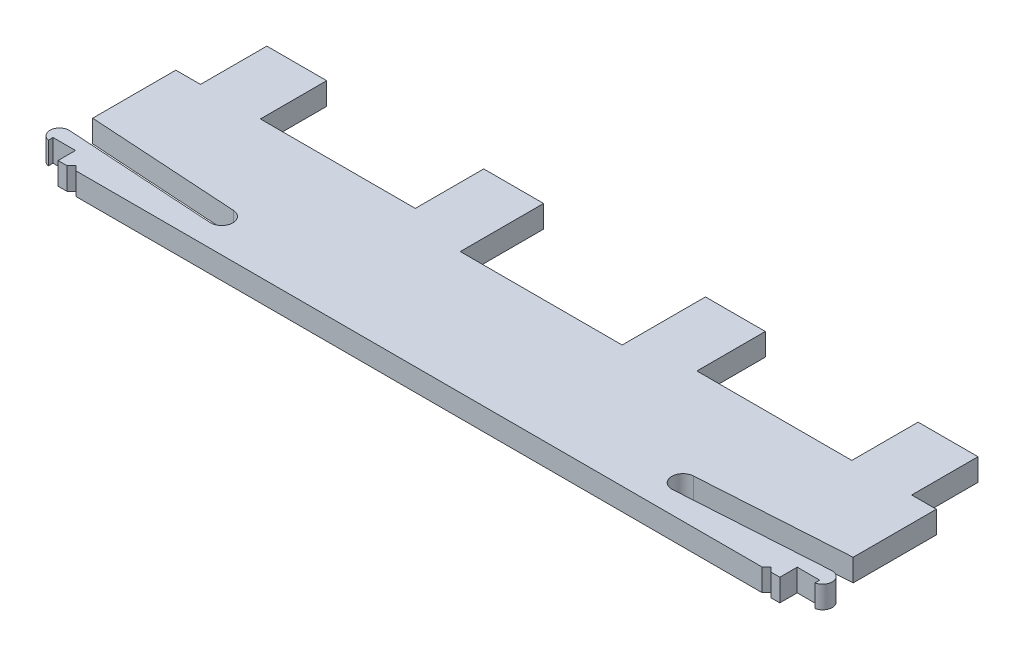
from build123d import *

# Parameters (mm, degrees)
BOSS_EXTRUDE1_DEPTH = 2.3622


with BuildPart() as part:
    # Sketch1 → Boss-Extrude1 (new body)
    with BuildSketch(Plane(origin=(0, 0, 0), x_dir=(1, 0, 0), z_dir=(0, 1, 0))):
        with BuildLine():
            Line((2.055202021, 14.546975478), (2.055202021, 5.72400467))
            Line((2.055202021, 5.72400467), (-13.894021226, 4.719731013))
            ThreePointArc((-13.894021226, 4.719731013), (-14.998563485, 3.466742259), (-13.745574731, 2.3622))
            Line((-13.745574731, 2.3622), (2.129425269, 3.361800046))
            ThreePointArc((2.129425269, 3.361800046), (3.201004497, 2.477166942), (2.3876, 1.350565462))
            Line((2.3876, 1.350565462), (2.3876, 1.846546672))
            Line((2.3876, 1.846546672), (0, 1.846546672))
            Line((0, 1.846546672), (0, 0))
            Line((0, 0), (-0.956548556, 0))
            Line((-0.956548556, 0), (-1.436625807, 0.480077251))
            Line((-1.436625807, 0.480077251), (-1.916703058, 0))
            Line((-1.916703058, 0), (-74.6432929, 0))
            Line((-74.6432929, 0), (-75.123370151, 0.480077251))
            Line((-75.123370151, 0.480077251), (-75.603447402, 0))
            Line((-75.603447402, 0), (-76.559995958, 0))
            Line((-76.559995958, 0), (-76.559995958, 1.846546672))
            Line((-76.559995958, 1.846546672), (-78.947595958, 1.846546672))
            Line((-78.947595958, 1.846546672), (-78.947595958, 1.350565462))
            ThreePointArc((-78.947595958, 1.350565462), (-79.761000455, 2.477166942), (-78.689421226, 3.361800046))
            Line((-78.689421226, 3.361800046), (-62.814421226, 2.3622))
            ThreePointArc((-62.814421226, 2.3622), (-61.561432472, 3.466742259), (-62.665974731, 4.719731013))
            Line((-62.665974731, 4.719731013), (-78.615197979, 5.72400467))
            Line((-78.615197979, 5.72400467), (-78.615197979, 14.546975478))
            Line((-78.615197979, 14.546975478), (-75.998997979, 14.546975478))
            Line((-75.998997979, 14.546975478), (-75.998997979, 21.582775478))
            Line((-75.998997979, 21.582775478), (-69.648997979, 21.582775478))
            Line((-69.648997979, 21.582775478), (-69.648997979, 14.546975478))
            Line((-69.648997979, 14.546975478), (-53.215197979, 14.546975478))
            Line((-53.215197979, 14.546975478), (-53.215197979, 21.806295525))
            Line((-53.215197979, 21.806295525), (-46.865197979, 21.806295525))
            Line((-46.865197979, 21.806295525), (-46.865197979, 12.967095525))
            Line((-46.865197979, 12.967095525), (-29.694797979, 12.967095525))
            Line((-29.694797979, 12.967095525), (-29.694797979, 21.806295525))
            Line((-29.694797979, 21.806295525), (-23.344797979, 21.806295525))
            Line((-23.344797979, 21.806295525), (-23.344797979, 14.546975478))
            Line((-23.344797979, 14.546975478), (-6.910997979, 14.546975478))
            Line((-6.910997979, 14.546975478), (-6.910997979, 21.582775478))
            Line((-6.910997979, 21.582775478), (-0.560997979, 21.582775478))
            Line((-0.560997979, 21.582775478), (-0.560997979, 14.546975478))
            Line((-0.560997979, 14.546975478), (2.055202021, 14.546975478))
        make_face()
    extrude(amount=BOSS_EXTRUDE1_DEPTH)


solid = part.part
